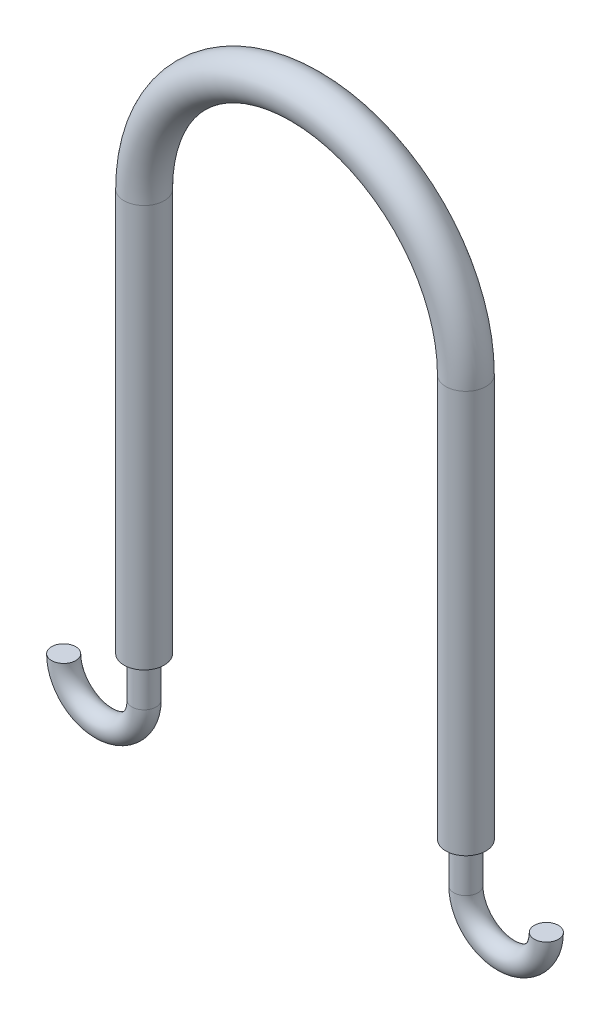
from build123d import *

# Parameters (mm, degrees)
SWEEP1_PROFILE_R = 6.35
SWEEP2_PROFILE_R = 3.81
SWEEP3_PROFILE_R = 3.81


with BuildPart() as part:
    # Sweep1: sweep along a path in Sketch1
    with BuildLine(Plane.XY) as sweep1_path:
        Line((51.267145729, -32.523030341), (51.267145729, 94.476969659))
        ThreePointArc((51.267145729, 94.476969659), (0.467145729, 145.276969659), (-50.332854271, 94.476969659))
        Line((-50.332854271, 94.476969659), (-50.332854271, -32.523030341))
    # Sweep1 profile (on start of the path) → Sweep1 (sweep)
    with BuildSketch(Plane(origin=(51.267145729, -32.523030341, 0), x_dir=(0, 0, 1), z_dir=(0, 1, 0))):
        Circle(SWEEP1_PROFILE_R)
    sweep(path=sweep1_path.line)

    # Sweep2: sweep along a path in Sketch8
    with BuildLine(Plane.XY) as sweep2_path:
        Line((-50.332854271, -32.523030341), (-50.332854271, -45.223030341))
        ThreePointArc((-50.332854271, -45.223030341), (-63.032854271, -57.923030341), (-75.732854271, -45.223030341))
    # Sweep2 profile (on start of the path) → Sweep2 (sweep)
    with BuildSketch(Plane(origin=(-50.332854271, -32.523030341, 0), x_dir=(0, 0, -1), z_dir=(0, -1, 0))):
        Circle(SWEEP2_PROFILE_R)
    sweep(path=sweep2_path.line)

    # Sweep3: sweep along a path in Sketch16
    with BuildLine(Plane.XY) as sweep3_path:
        Line((51.267145729, -32.523030341), (51.267145729, -45.223030341))
        ThreePointArc((51.267145729, -45.223030341), (63.967145729, -57.923030341), (76.667145729, -45.223030341))
    # Sweep3 profile (on start of the path) → Sweep3 (sweep)
    with BuildSketch(Plane(origin=(51.267145729, -32.523030341, 0), x_dir=(-1, 0, 0), z_dir=(0, -1, 0))):
        Circle(SWEEP3_PROFILE_R)
    sweep(path=sweep3_path.line)


solid = part.part
